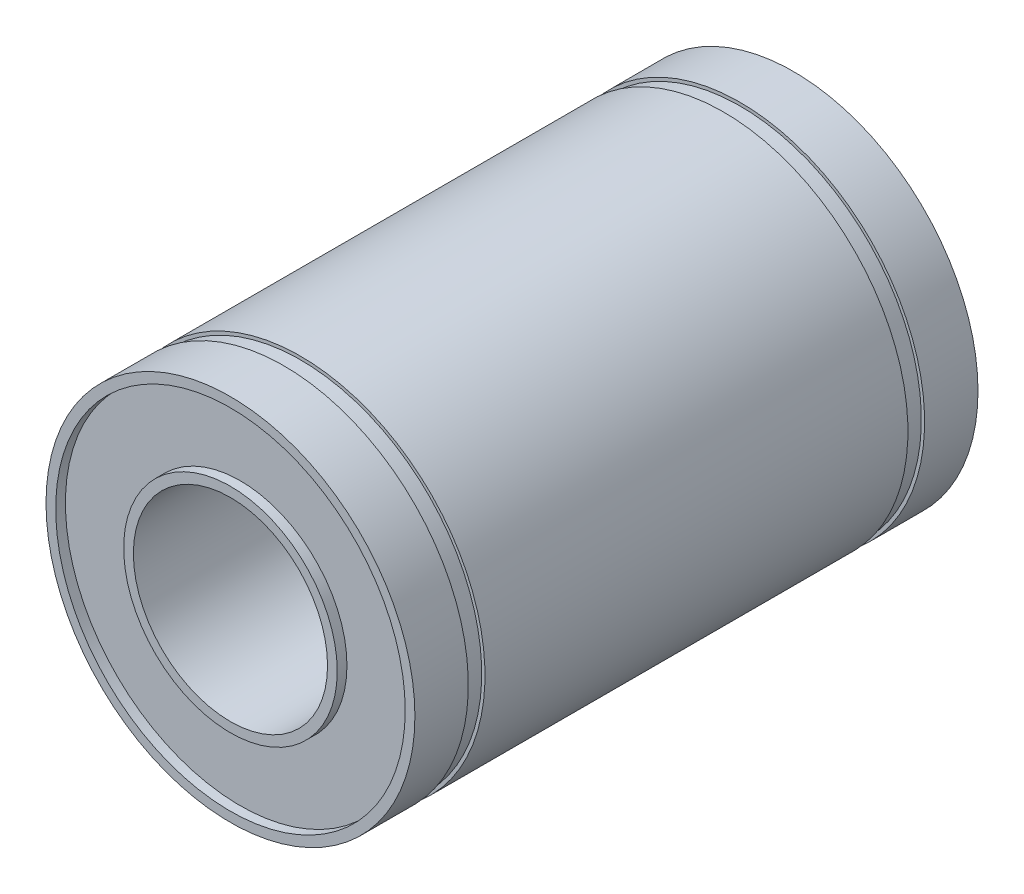
from build123d import *

# Parameters (mm, degrees)
SKETCH1_R           = 9.5
SKETCH1_R_2         = 5
BOSS_EXTRUDE1_DEPTH = 14.5
SKETCH2_W           = 0.167239634
SKETCH2_H           = 0.858355734
SKETCH3_R           = 9
SKETCH3_R_2         = 5.5
CUT_EXTRUDE1_DEPTH  = 0.5


with BuildPart() as part:
    # Sketch1 → Boss-Extrude1 (new body, symmetric)
    with BuildSketch(Plane.XY):
        Circle(SKETCH1_R)
        Circle(SKETCH1_R_2, mode=Mode.SUBTRACT)
    extrude(amount=BOSS_EXTRUDE1_DEPTH, both=True)

    # Sketch2 → Cut-Revolve1 (revolve, cut)
    with BuildSketch(Plane(origin=(0, 0, 0), x_dir=(1, 0, 0), z_dir=(0, 1, 0))):
        with Locations((9.416380183, -11.320822133)):
            Rectangle(SKETCH2_W, SKETCH2_H)
        with Locations((9.416380183, 11.320822133)):
            Rectangle(SKETCH2_W, SKETCH2_H)
    revolve(axis=Axis((0, 0, 0), (0, 0, 1)), mode=Mode.SUBTRACT)

    # Sketch3 → Cut-Extrude1 (cut)
    with BuildSketch(Plane.XY.offset(14.5)):
        Circle(SKETCH3_R)
        Circle(SKETCH3_R_2, mode=Mode.SUBTRACT)
    cut_extrude1 = extrude(amount=-CUT_EXTRUDE1_DEPTH, mode=Mode.SUBTRACT)

    # Mirror1: Cut-Extrude1 across plane
    add(cut_extrude1.mirror(Plane.XY), mode=Mode.SUBTRACT)


solid = part.part
